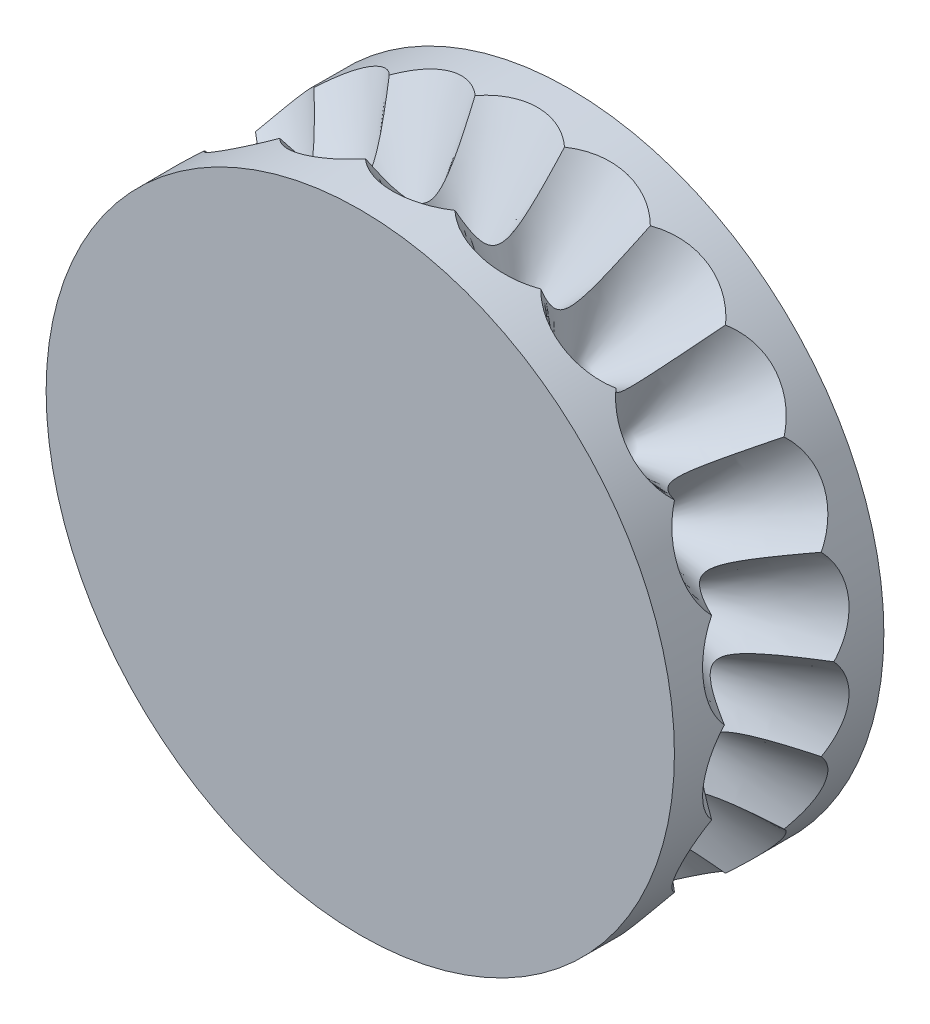
from build123d import *

# Parameters (mm, degrees)
SKETCH1_R           = 6
BOSS_EXTRUDE1_DEPTH = 2
CIRPATTERN1_COUNT   = 22


with BuildPart() as part:
    # Sketch1 → Boss-Extrude1 (new body, symmetric)
    with BuildSketch(Plane.XY):
        Circle(SKETCH1_R)
    extrude(amount=BOSS_EXTRUDE1_DEPTH, both=True)

    # Sketch2 → Cut-Revolve1 (revolve, cut)
    with BuildSketch(Plane.XY):
        Polygon((0, 3.6), (2.341448702, 7.655508115), (0, 7.655508115), align=None)
    cut_revolve1 = revolve(axis=Axis((0, 0, 0), (0, 1, 0)), mode=Mode.SUBTRACT)

    # CirPattern1: Cut-Revolve1 ×22 about axis
    cirpattern1_axis = Axis((0, 0, 2), (0, 0, -1))
    for i in range(1, CIRPATTERN1_COUNT):
        add(cut_revolve1.rotate(cirpattern1_axis, i * 360 / CIRPATTERN1_COUNT), mode=Mode.SUBTRACT)


solid = part.part
